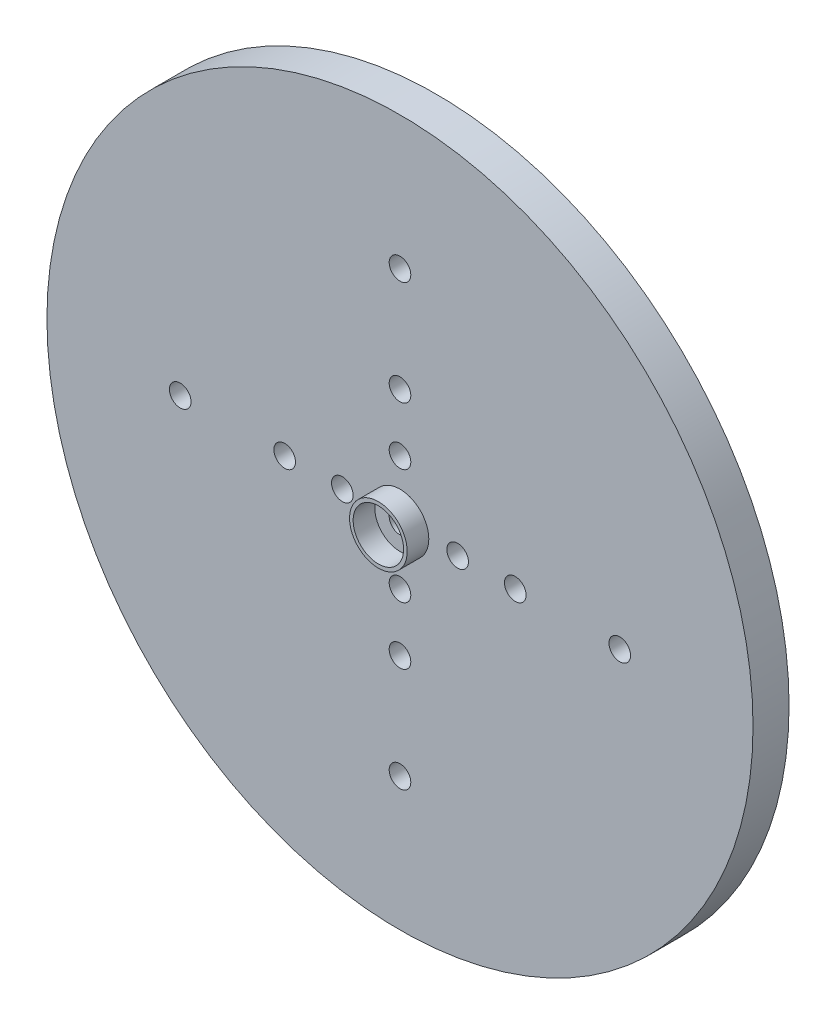
from build123d import *

# Parameters (mm, degrees)
SKETCH1_R           = 49
BOSS_EXTRUDE1_DEPTH = 5
SKETCH2_R           = 4.5
SKETCH2_R_2         = 3
BOSS_EXTRUDE2_DEPTH = 4
SKETCH2_2_R         = 4.5
SKETCH2_2_R_2       = 3
BOSS_EXTRUDE3_DEPTH = 4
SKETCH3_R           = 4
SKETCH3_R_2         = 3.5
BOSS_EXTRUDE4_DEPTH = 3
SKETCH4_R           = 1.5
CUT_EXTRUDE1_DEPTH  = 5
SKETCH5_R           = 1.5
CUT_EXTRUDE2_DEPTH  = 5


with BuildPart() as part:
    # Sketch1 → Boss-Extrude1 (new body)
    with BuildSketch(Plane.XY):
        with Locations((-26.650582962, 0)):
            Circle(SKETCH1_R)
    extrude(amount=BOSS_EXTRUDE1_DEPTH)

    # Sketch2 → Boss-Extrude2 (add)
    with BuildSketch(Plane(origin=(0, 0, 0), x_dir=(-1, 0, 0), z_dir=(0, 0, -1))):
        with Locations((26.650582962, 0)):
            Circle(SKETCH2_R)
        with Locations((26.650582962, 0)):
            Circle(SKETCH2_R_2, mode=Mode.SUBTRACT)
    extrude(amount=-BOSS_EXTRUDE2_DEPTH)

    # Sketch2_2 → Boss-Extrude3 (add)
    with BuildSketch(Plane(origin=(0, 0, 0), x_dir=(-1, 0, 0), z_dir=(0, 0, -1))):
        with Locations((26.650582962, 0)):
            Circle(SKETCH2_2_R)
        with Locations((26.650582962, 0)):
            Circle(SKETCH2_2_R_2, mode=Mode.SUBTRACT)
    extrude(amount=BOSS_EXTRUDE3_DEPTH)

    # Sketch3 → Boss-Extrude4 (add)
    with BuildSketch(Plane.XY.offset(5)):
        with Locations((-26.650582962, 0)):
            Circle(SKETCH3_R)
        with Locations((-26.650582962, 0)):
            Circle(SKETCH3_R_2, mode=Mode.SUBTRACT)
    extrude(amount=BOSS_EXTRUDE4_DEPTH)

    # Sketch4 → Cut-Extrude1 (cut)
    with BuildSketch(Plane.XY.offset(5)):
        with Locations((-26.650582962, 0)):
            Circle(SKETCH4_R)
    extrude(amount=-CUT_EXTRUDE1_DEPTH, mode=Mode.SUBTRACT)

    # Sketch5 → Cut-Extrude2 (cut)
    with BuildSketch(Plane.XY.offset(5)):
        with Locations((-34.650582962, 0)):
            Circle(SKETCH5_R)
        with Locations((-42.650582962, 0)):
            Circle(SKETCH5_R)
        with Locations((-57.150582962, 0)):
            Circle(SKETCH5_R)
        with Locations((-26.650582962, 8)):
            Circle(SKETCH5_R)
        with Locations((-26.650582962, 16)):
            Circle(SKETCH5_R)
        with Locations((-26.650582962, 30.5)):
            Circle(SKETCH5_R)
        with Locations((-18.650582962, 0)):
            Circle(SKETCH5_R)
        with Locations((-10.650582962, 0)):
            Circle(SKETCH5_R)
        with Locations((3.849417038, 0)):
            Circle(SKETCH5_R)
        with Locations((-26.650582962, -8)):
            Circle(SKETCH5_R)
        with Locations((-26.650582962, -16)):
            Circle(SKETCH5_R)
        with Locations((-26.650582962, -30.5)):
            Circle(SKETCH5_R)
    extrude(amount=-CUT_EXTRUDE2_DEPTH, mode=Mode.SUBTRACT)


solid = part.part
